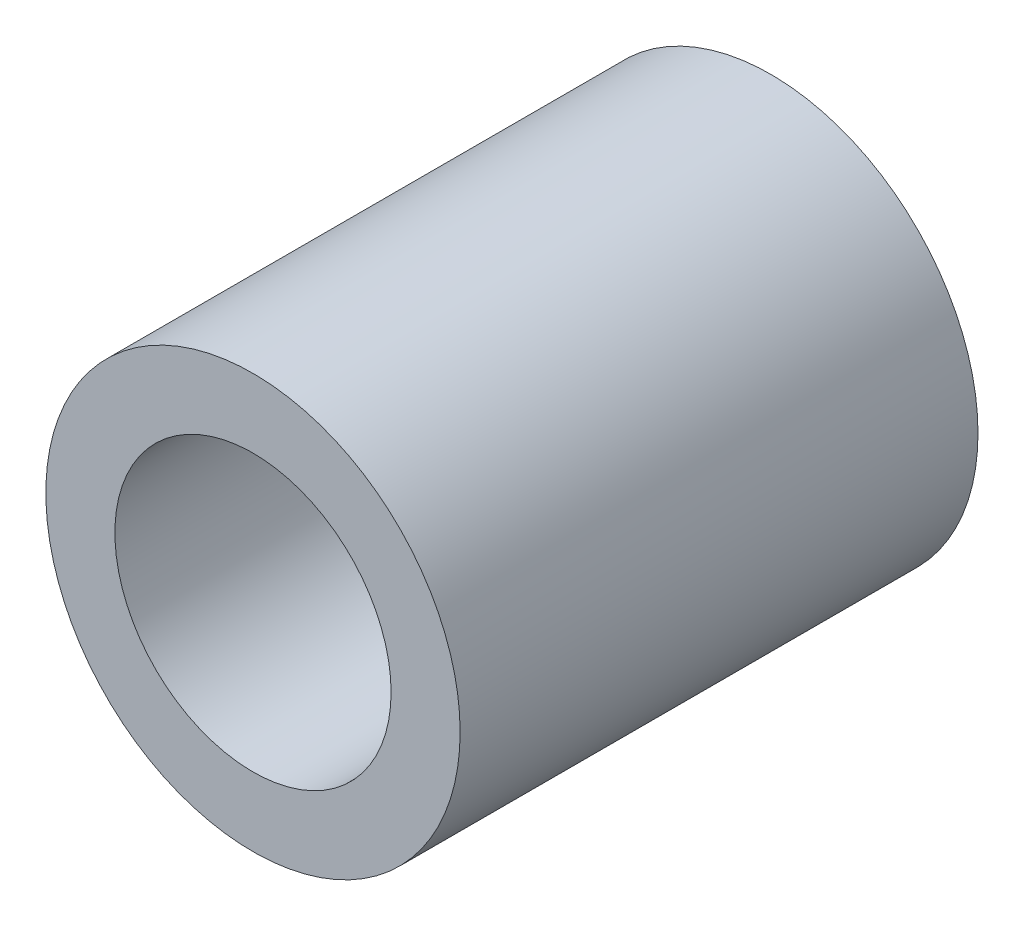
from build123d import *

# Parameters (mm, degrees)
SKETCH1_R           = 12
SKETCH1_R_2         = 8
BOSS_EXTRUDE1_DEPTH = 30


with BuildPart() as part:
    # Sketch1 → Boss-Extrude1 (new body)
    with BuildSketch(Plane.XY):
        Circle(SKETCH1_R)
        Circle(SKETCH1_R_2, mode=Mode.SUBTRACT)
    extrude(amount=BOSS_EXTRUDE1_DEPTH)


solid = part.part
